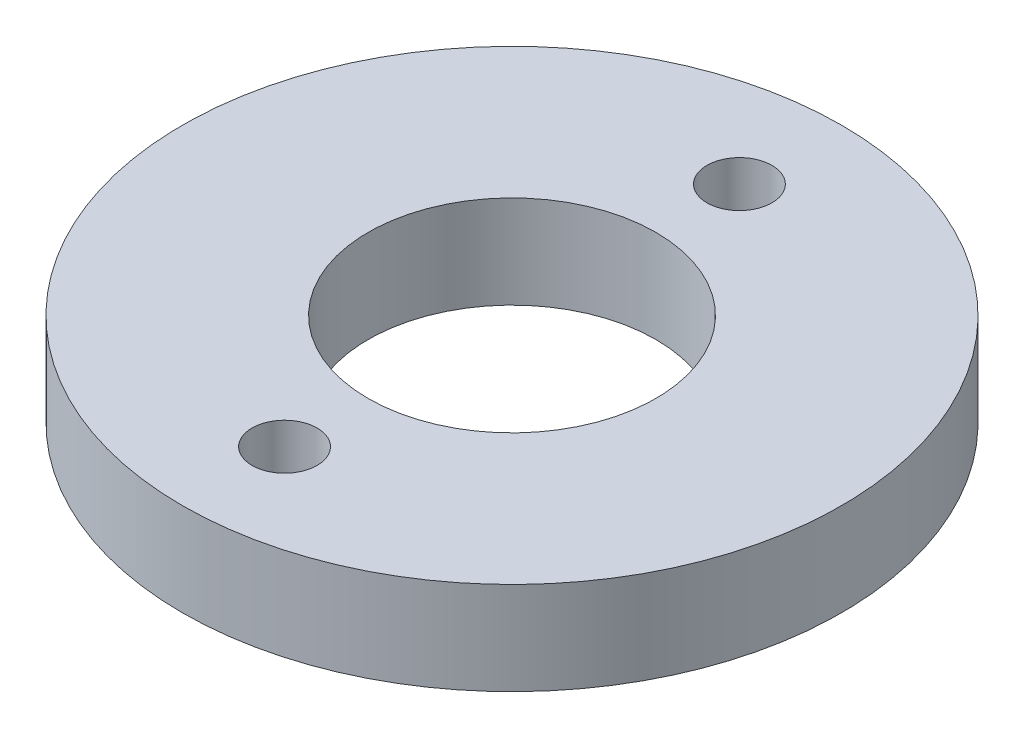
from build123d import *

# Parameters (mm, degrees)
SKETCH1_R           = 10.65
SKETCH1_R_2         = 4.65
BOSS_EXTRUDE1_DEPTH = 3
SKETCH2_R           = 1.05
CUT_EXTRUDE1_DEPTH  = 3


with BuildPart() as part:
    # Sketch1 → Boss-Extrude1 (new body)
    with BuildSketch(Plane(origin=(0, 0, 0), x_dir=(1, 0, 0), z_dir=(0, 1, 0))):
        Circle(SKETCH1_R)
        Circle(SKETCH1_R_2, mode=Mode.SUBTRACT)
    extrude(amount=BOSS_EXTRUDE1_DEPTH)

    # Sketch2 → Cut-Extrude1 (cut)
    with BuildSketch(Plane(origin=(0, 3, 0), x_dir=(1, 0, 0), z_dir=(0, 1, 0))):
        with Locations((0, 7.35)):
            Circle(SKETCH2_R)
        with Locations((0, -7.35)):
            Circle(SKETCH2_R)
    extrude(amount=-CUT_EXTRUDE1_DEPTH, mode=Mode.SUBTRACT)


solid = part.part
